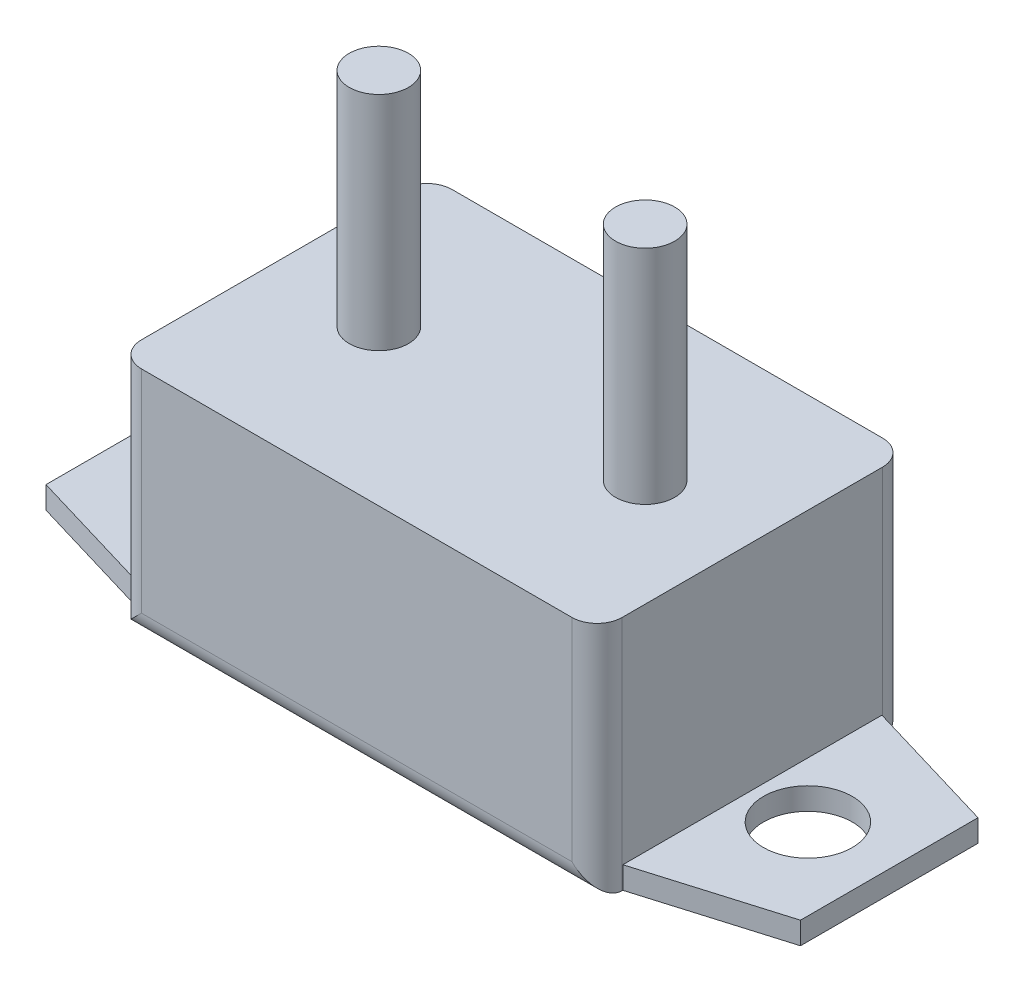
from build123d import *

# Parameters (mm, degrees)
CROQUIS1_W              = 32.5
CROQUIS1_H              = 21
SALIENTE_EXTRUIR1_DEPTH = 16
CROQUIS2_R              = 2
SALIENTE_EXTRUIR2_DEPTH = 15
CROQUIS3_R              = 3
SALIENTE_EXTRUIR3_DEPTH = 1.5
REDONDEO1_R             = 1.7


with BuildPart() as part:
    # Croquis1 → Saliente-Extruir1 (new body)
    with BuildSketch(Plane(origin=(0, 0, 0), x_dir=(1, 0, 0), z_dir=(0, 1, 0))):
        Rectangle(CROQUIS1_W, CROQUIS1_H)
    extrude(amount=SALIENTE_EXTRUIR1_DEPTH)

    # Croquis2 → Saliente-Extruir2 (add)
    with BuildSketch(Plane(origin=(0, 16, 0), x_dir=(1, 0, 0), z_dir=(0, 1, 0))):
        with Locations((-9, 0)):
            Circle(CROQUIS2_R)
        with Locations((9, 0)):
            Circle(CROQUIS2_R)
    extrude(amount=SALIENTE_EXTRUIR2_DEPTH)

    # Croquis3 → Saliente-Extruir3 (add)
    with BuildSketch(Plane.XZ):
        Polygon((-16.25, 8.754302239), (-25.5, 6), (-25.5, -6), (-16.25, -8.754302239), align=None)
        with Locations((-20, 0)):
            Circle(CROQUIS3_R, mode=Mode.SUBTRACT)
        Polygon((16.25, -8.754302239), (25.5, -6), (25.5, 6), (16.25, 8.754302239), align=None)
        with Locations((20, 0)):
            Circle(CROQUIS3_R, mode=Mode.SUBTRACT)
    extrude(amount=-SALIENTE_EXTRUIR3_DEPTH)

    # Redondeo1
    redondeo1_edges = [part.edges().sort_by_distance(p)[0] for p in [
        (0, 0, 10.5),
        (0, 0, -10.5),
        (16.25, 8, 10.5),
        (-16.25, 8, 10.5),
        (-16.25, 8, -10.5),
        (16.25, 8, -10.5),
    ]]
    fillet(redondeo1_edges, radius=REDONDEO1_R)


solid = part.part
